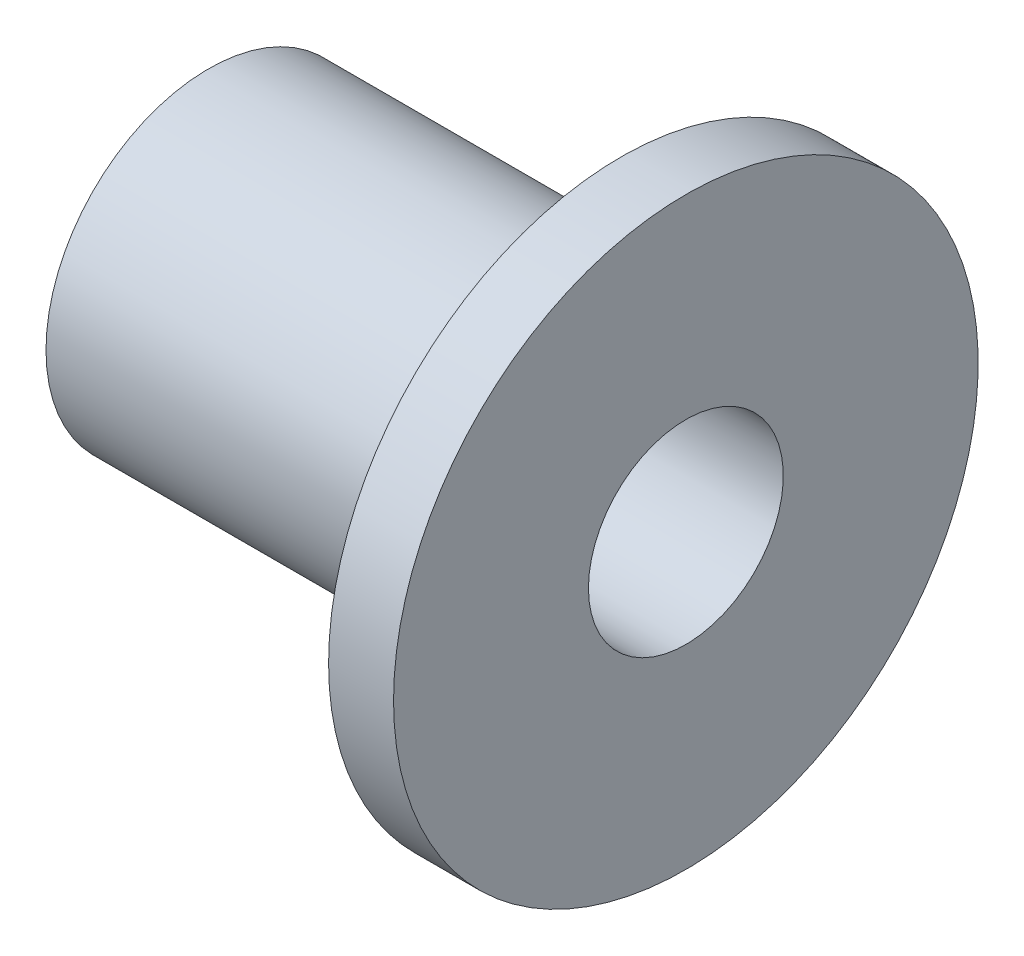
from build123d import *


with BuildPart() as part:
    # Sketch1 → Revolve1 (revolve)
    with BuildSketch(Plane.XY):
        Polygon((0, 3), (14.7, 3), (14.7, 9), (12.7, 9), (12.7, 5), (0, 5), align=None)
    revolve(axis=Axis((0, 0, 0), (1, 0, 0)))


solid = part.part
